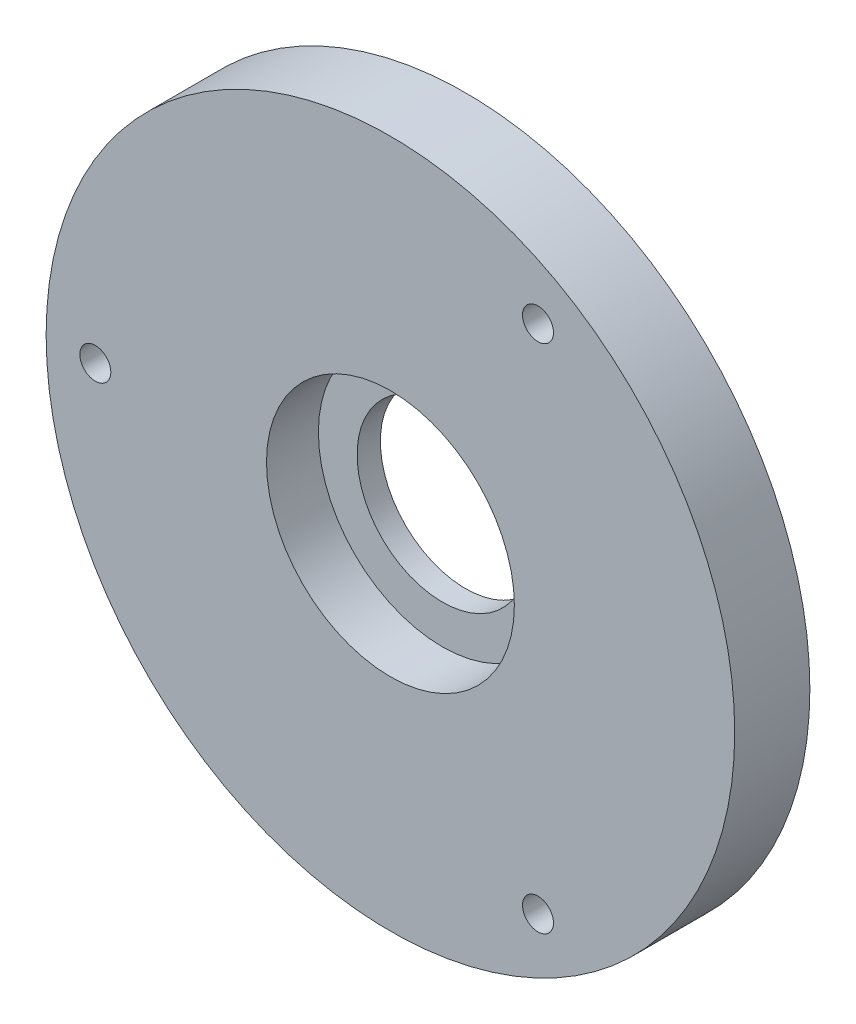
from build123d import *

# Parameters (mm, degrees)
SKETCH1_R           = 44.45
BOSS_EXTRUDE1_DEPTH = 9.7
SKETCH2_R           = 16
CUT_EXTRUDE1_DEPTH  = 6.7
SKETCH3_R           = 11
CUT_EXTRUDE2_DEPTH  = 9
SKETCH5_R           = 2
CUT_EXTRUDE4_DEPTH  = 10.7


with BuildPart() as part:
    # Sketch1 → Boss-Extrude1 (new body)
    with BuildSketch(Plane.XY):
        Circle(SKETCH1_R)
    extrude(amount=BOSS_EXTRUDE1_DEPTH)

    # Sketch2 → Cut-Extrude1 (cut)
    with BuildSketch(Plane.XY.offset(9.7)):
        Circle(SKETCH2_R)
    extrude(amount=-CUT_EXTRUDE1_DEPTH, mode=Mode.SUBTRACT)

    # Sketch3 → Cut-Extrude2 (cut)
    with BuildSketch(Plane.XY.offset(3)):
        Circle(SKETCH3_R)
    extrude(amount=-CUT_EXTRUDE2_DEPTH, mode=Mode.SUBTRACT)

    # Sketch5 → Cut-Extrude4 (cut, through all)
    with BuildSketch(Plane(origin=(0, 0, 0), x_dir=(-1, 0, 0), z_dir=(0, 0, -1))):
        with Locations((38.1, 0)):
            Circle(SKETCH5_R)
        with Locations((-19.05, -32.995567884)):
            Circle(SKETCH5_R)
        with Locations((-19.05, 32.995567884)):
            Circle(SKETCH5_R)
    extrude(amount=-CUT_EXTRUDE4_DEPTH, mode=Mode.SUBTRACT)


solid = part.part
